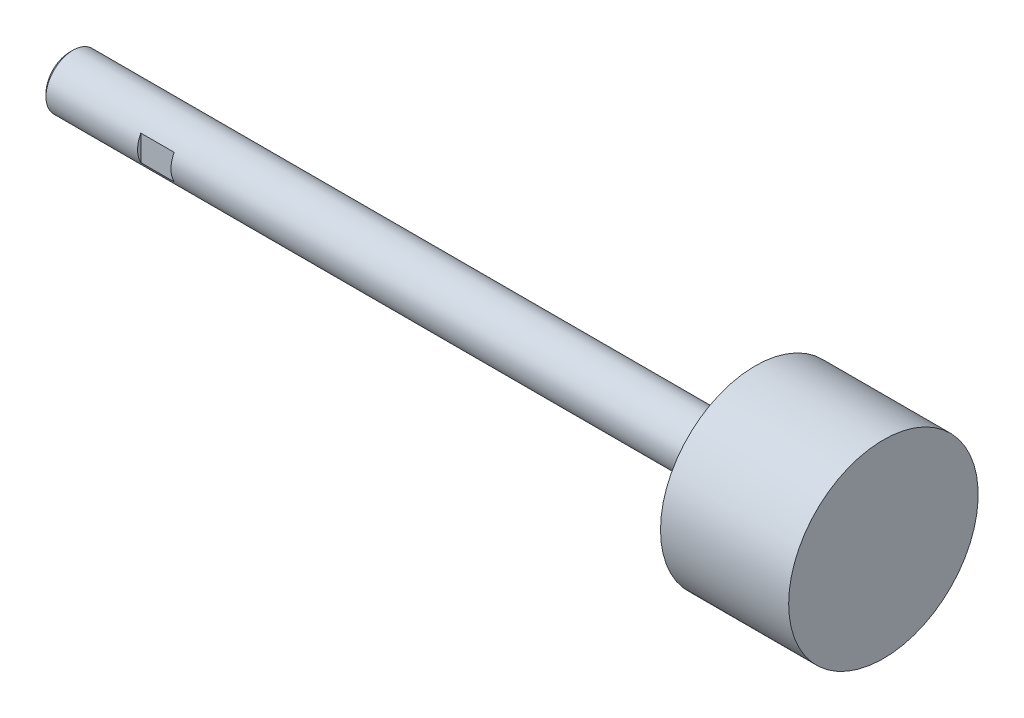
from build123d import *

# Parameters (mm, degrees)
SKETCH3_W          = 25.4
SKETCH3_H          = 25.4
SKETCH3_W_2        = 11.176
SKETCH3_H_2        = 12.7
CUT_EXTRUDE1_DEPTH = 7.874


with BuildPart() as part:
    # Sketch1 → Revolve1 (revolve)
    with BuildSketch(Plane.XY):
        Polygon((-7.874, 0), (-7.874, 6.35), (131.445, 6.35), (131.445, 22.34565), (161.671, 22.34565), (161.671, 0), align=None)
    revolve(axis=Axis((161.671, 0, 0), (-1, 0, 0)))

    # Sketch2 → Revolve2 (revolve)
    with BuildSketch(Plane.XY):
        Polygon((-30.226, 0), (-30.226, 5.59435), (-29.47035, 6.35), (-7.874, 6.35), (-7.874, 0), align=None)
    revolve(axis=Axis((-7.874, 0, 0), (-1, 0, 0)))

    # Sketch3 → Cut-Extrude1 (cut)
    with BuildSketch(Plane(origin=(-7.874, 0, 0), x_dir=(0, 0, -1), z_dir=(1, 0, 0))):
        Rectangle(SKETCH3_W, SKETCH3_H)
        Rectangle(SKETCH3_W_2, SKETCH3_H_2, mode=Mode.SUBTRACT)
    extrude(amount=CUT_EXTRUDE1_DEPTH, mode=Mode.SUBTRACT)


solid = part.part
